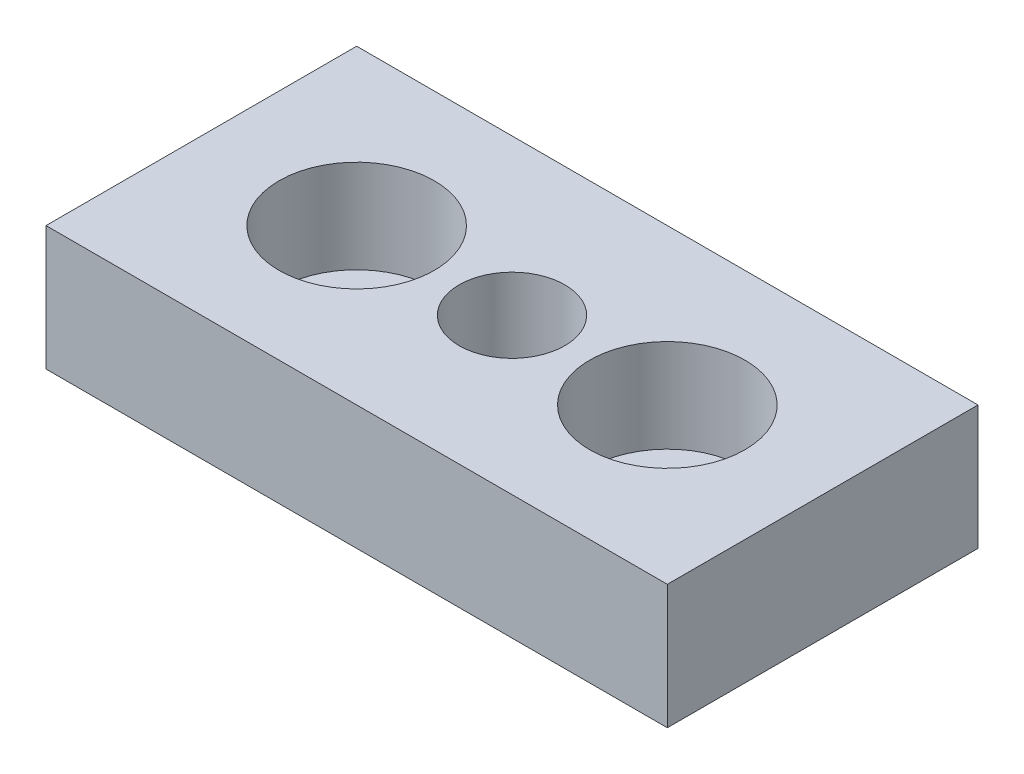
from build123d import *

# Parameters (mm, degrees)
SKETCH_1_W             = 60
SKETCH_1_H             = 30
EXTRUDE_1_DEPTH        = 12
HOLE_WIZARD_M121_D     = 10.2
HOLE_WIZARD_M121_DEPTH = 12


with BuildPart() as part:
    # Эскиз1 → Бобышка-Вытянуть1 (new body)
    with BuildSketch(Plane(origin=(0, 0, 0), x_dir=(1, 0, 0), z_dir=(0, 1, 0))):
        Rectangle(SKETCH_1_W, SKETCH_1_H)
    extrude(amount=EXTRUDE_1_DEPTH)

    # Эскиз2 → Вырез-Повернуть1 (revolve, cut)
    with BuildSketch(Plane.XY):
        Polygon((-22.5, 12), (-22.5, 3), (-19.5, 3), (-19.5, 0), (-15, 0), (-15, 12), align=None)
    cut_revolve_1 = revolve(axis=Axis((-15, 12, 0), (0, -1, 0)), mode=Mode.SUBTRACT)

    # Зеркальное отражение1: Вырез-Повернуть1 across plane
    add(cut_revolve_1.mirror(Plane(origin=(0, 0, 0), x_dir=(0, 0, 1), z_dir=(1, 0, 0))), mode=Mode.SUBTRACT)

    # Отверстие обработанное метчиком M121
    with Locations(Plane(origin=(0, 12, 0), x_dir=(1, 0, 0), z_dir=(0, 1, 0))):
        with Locations((0, 0)):
            Hole(HOLE_WIZARD_M121_D / 2, depth=HOLE_WIZARD_M121_DEPTH)


solid = part.part
